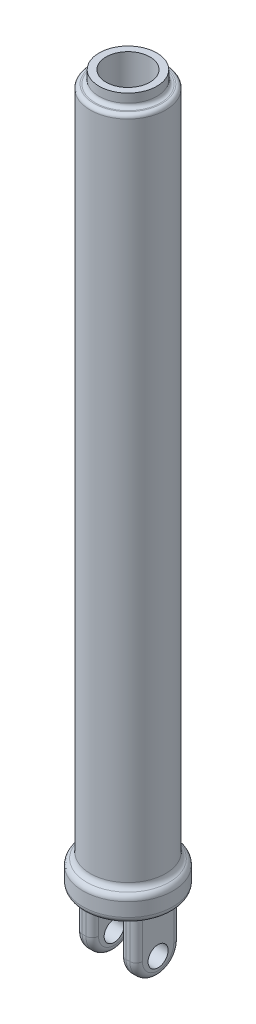
from build123d import *

# Parameters (mm, degrees)
SKETCH2_W           = 13
SKETCH2_H           = 35
BOSS_EXTRUDE1_DEPTH = 50
SKETCH3_R           = 8
CUT_EXTRUDE1_DEPTH  = 60.823854569
FILLET1_R           = 5


with BuildPart() as part:
    # Sketch1 → Revolve1 (revolve)
    with BuildSketch(Plane.XY):
        with BuildLine():
            Line((-30, 552), (-30, 24.977358367))
            ThreePointArc((-30, 24.977358367), (-30.790465371, 22.279244542), (-32.911927285, 20.434236936))
            ThreePointArc((-32.911927285, 20.434236936), (-35.033389198, 18.58922933), (-35.823854569, 15.891115505))
            Line((-35.823854569, 15.891115505), (-35.823854569, 5))
            ThreePointArc((-35.823854569, 5), (-34.359388475, 1.464466094), (-30.823854569, 0))
            Line((-30.823854569, 0), (0, 0))
            Line((0, 0), (0, 40))
            Line((0, 40), (-17.5, 40))
            Line((-17.5, 40), (-17.5, 565))
            Line((-17.5, 565), (-23, 565))
            Line((-23, 565), (-23, 558))
            ThreePointArc((-23, 558), (-23.878679656, 555.878679656), (-26, 555))
            Line((-26, 555), (-27, 555))
            ThreePointArc((-27, 555), (-29.121320344, 554.121320344), (-30, 552))
        make_face()
    revolve(axis=Axis((0, 40, 0), (0, -1, 0)))

    # Sketch2 → Boss-Extrude1 (add)
    with BuildSketch(Plane.XZ):
        with Locations((17.5, 0)):
            Rectangle(SKETCH2_W, SKETCH2_H)
        with Locations((-17.5, 0)):
            Rectangle(SKETCH2_W, SKETCH2_H)
    extrude(amount=BOSS_EXTRUDE1_DEPTH)

    # Sketch3 → Cut-Extrude1 (cut, through all)
    with BuildSketch(Plane(origin=(24, 0, 0), x_dir=(0, 0, -1), z_dir=(1, 0, 0))):
        with BuildLine():
            ThreePointArc((0, -50), (-12.374368671, -44.874368671), (-17.5, -32.5))
            Line((-17.5, -32.5), (-17.5, -50))
            Line((-17.5, -50), (0, -50))
        make_face()
        with BuildLine():
            ThreePointArc((17.5, -32.5), (12.374368671, -44.874368671), (0, -50))
            Line((0, -50), (17.5, -50))
            Line((17.5, -50), (17.5, -32.5))
        make_face()
        with Locations((0, -35)):
            Circle(SKETCH3_R)
    extrude(amount=-CUT_EXTRUDE1_DEPTH, mode=Mode.SUBTRACT)

    # Fillet1
    fillet1_edges = [part.edges().sort_by_distance(p)[0] for p in [
        (-11, -16.25, -17.5),
        (-24, -16.25, -17.5),
        (24, -16.25, -17.5),
        (11, -16.25, -17.5),
        (24, -50, 0),
        (11, -50, 0),
        (-11, -50, 0),
        (-24, -50, 0),
        (-24, -16.25, 17.5),
        (-11, -16.25, 17.5),
        (11, -16.25, 17.5),
        (24, -16.25, 17.5),
    ]]
    fillet(fillet1_edges, radius=FILLET1_R)


solid = part.part
